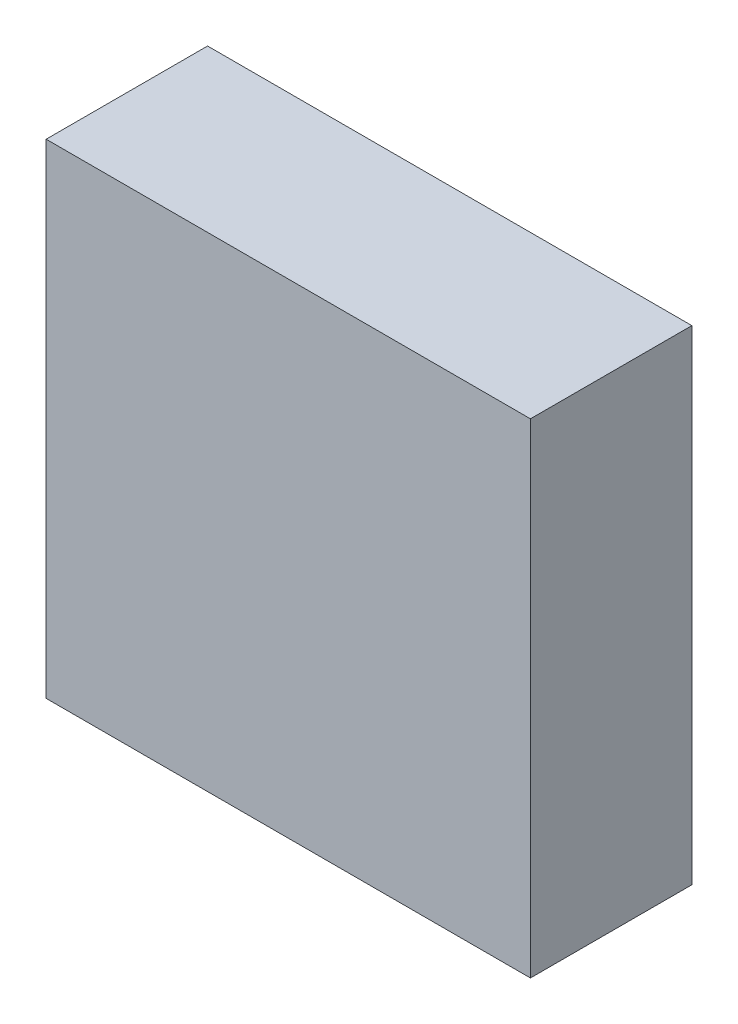
from build123d import *

# Parameters (mm, degrees)
ESQUISSE1_W        = 3
ESQUISSE1_H        = 3
BOSS_EXTRU_1_DEPTH = 1


with BuildPart() as part:
    # Esquisse1 → Boss.-Extru.1 (new body)
    with BuildSketch(Plane.XY):
        with Locations((1.5, 1.5)):
            Rectangle(ESQUISSE1_W, ESQUISSE1_H)
    extrude(amount=BOSS_EXTRU_1_DEPTH)


solid = part.part
